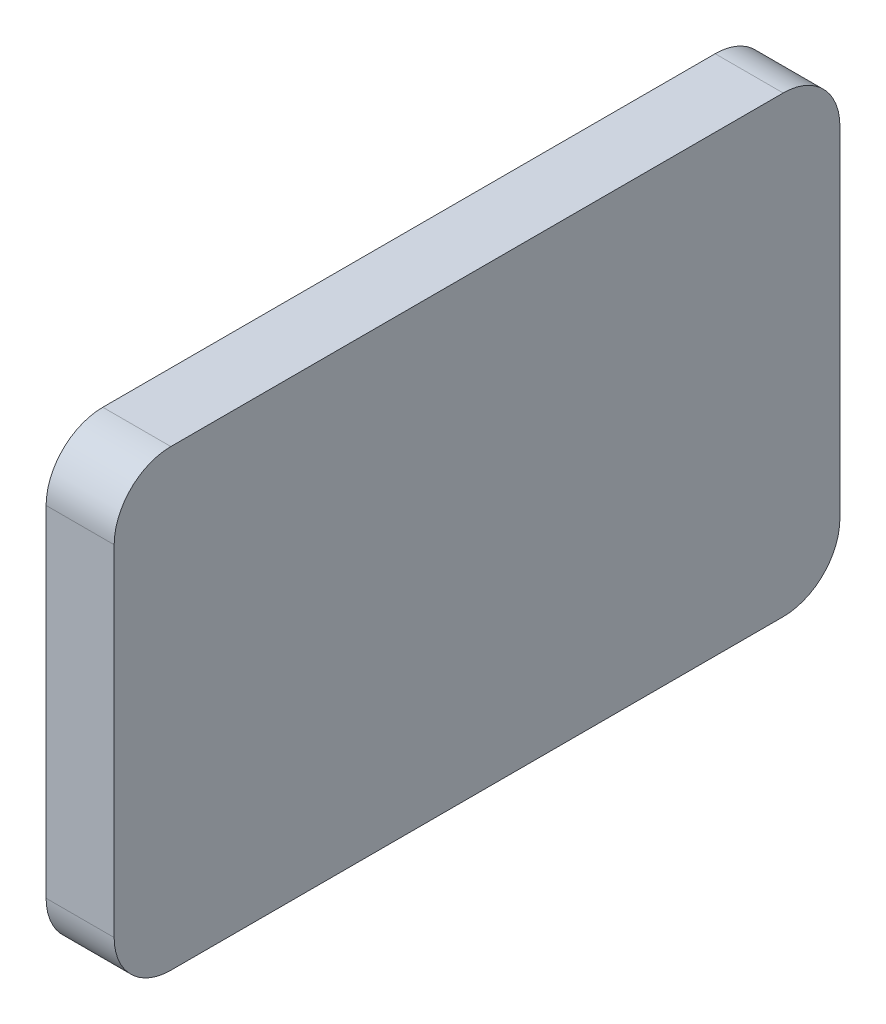
from build123d import *

# Parameters (mm, degrees)
EXTRUDE_1_DEPTH = 6


with BuildPart() as part:
    # 草图1 → 凸台-拉伸1 (new body)
    with BuildSketch(Plane(origin=(0, 0, 0), x_dir=(0, 0, -1), z_dir=(1, 0, 0))):
        with BuildLine():
            Line((-27, 20), (27, 20))
            ThreePointArc((27, 20), (30.535533906, 18.535533906), (32, 15))
            Line((32, 15), (32, -15))
            ThreePointArc((32, -15), (30.535533906, -18.535533906), (27, -20))
            Line((27, -20), (-27, -20))
            ThreePointArc((-27, -20), (-30.535533906, -18.535533906), (-32, -15))
            Line((-32, -15), (-32, 15))
            ThreePointArc((-32, 15), (-30.535533906, 18.535533906), (-27, 20))
        make_face()
    extrude(amount=EXTRUDE_1_DEPTH)


solid = part.part
